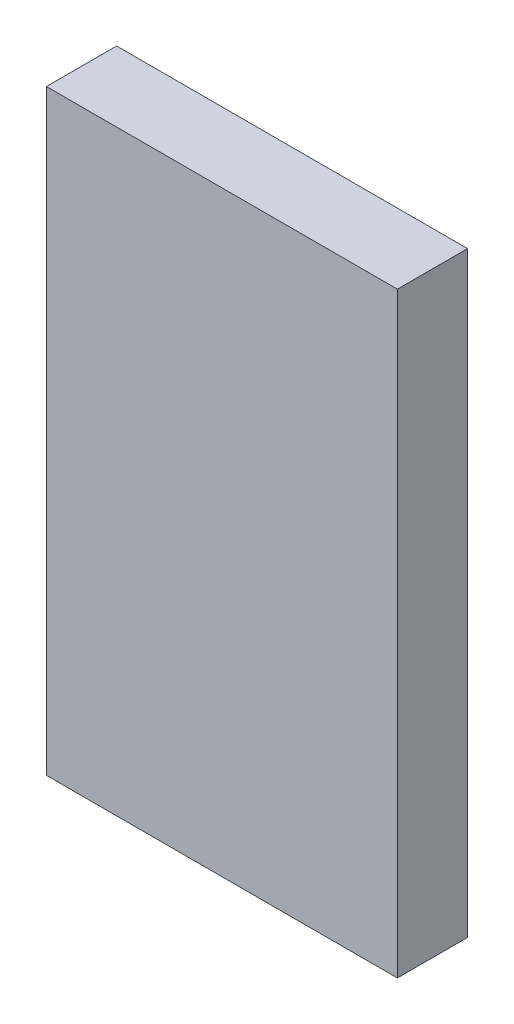
from build123d import *

# Parameters (mm, degrees)
SKETCH1_W        = 20
SKETCH1_H        = 34
JOINT_BODY_DEPTH = 4


with BuildPart() as part:
    # Sketch1 → Joint Body (new body)
    with BuildSketch(Plane.XY):
        with Locations((10, 17)):
            Rectangle(SKETCH1_W, SKETCH1_H)
    extrude(amount=JOINT_BODY_DEPTH)


solid = part.part
